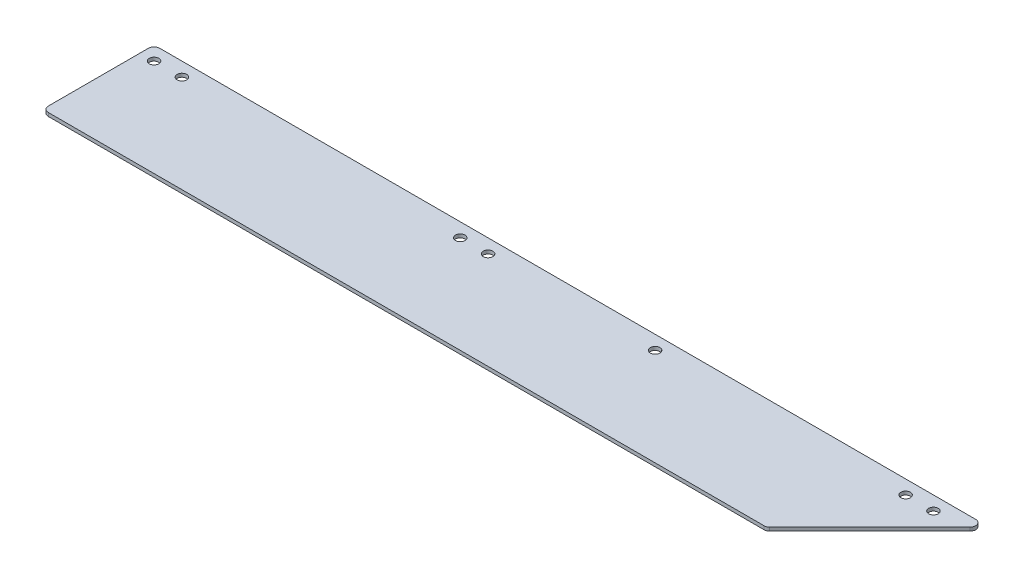
from build123d import *

# Parameters (mm, degrees)
SKETCH1_R           = 2.1828125
BOSS_EXTRUDE1_DEPTH = 1.5875


with BuildPart() as part:
    # Sketch1 → Boss-Extrude1 (new body)
    with BuildSketch(Plane(origin=(0, 0, 0), x_dir=(1, 0, 0), z_dir=(0, 1, 0))):
        with BuildLine():
            Line((2.54, 0), (374.867897552, 0))
            ThreePointArc((374.867897552, 0), (377.214551564, -1.567984082), (376.663948776, -4.336051224))
            Line((376.663948776, -4.336051224), (330.943948776, -50.056051224))
            ThreePointArc((330.943948776, -50.056051224), (330.11991347, -50.606654013), (329.147897552, -50.8))
            Line((329.147897552, -50.8), (2.54, -50.8))
            ThreePointArc((2.54, -50.8), (0.743948776, -50.056051224), (0, -48.26))
            Line((0, -48.26), (0, -2.54))
            ThreePointArc((0, -2.54), (0.743948776, -0.743948776), (2.54, 0))
        make_face()
        with Locations((6.35, -6.35)):
            Circle(SKETCH1_R, mode=Mode.SUBTRACT)
        with Locations((19.05, -6.35)):
            Circle(SKETCH1_R, mode=Mode.SUBTRACT)
        with Locations((146.05, -6.35)):
            Circle(SKETCH1_R, mode=Mode.SUBTRACT)
        with Locations((158.75, -6.35)):
            Circle(SKETCH1_R, mode=Mode.SUBTRACT)
        with Locations((349.25, -6.35)):
            Circle(SKETCH1_R, mode=Mode.SUBTRACT)
        with Locations((361.95, -6.35)):
            Circle(SKETCH1_R, mode=Mode.SUBTRACT)
        with Locations((234.95, -6.35)):
            Circle(SKETCH1_R, mode=Mode.SUBTRACT)
    extrude(amount=BOSS_EXTRUDE1_DEPTH)


solid = part.part
